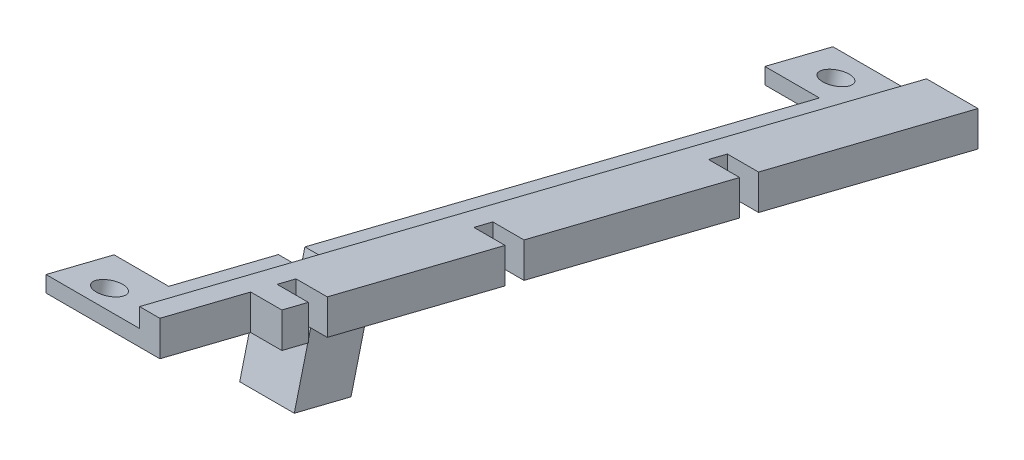
from build123d import *

# Parameters (mm, degrees)
SIDE_COMB_DEPTH           = 4
SIDE_COMB_2_DEPTH         = 4
SIDE_COMB_3_DEPTH         = 4
SIDE_COMB_4_DEPTH         = 4
SIDE_SPACER_DEPTH         = 2.6
NARROW_SUPPORT_DEPTH      = 5
SCREW_TABS_DEPTH          = 7
SKETCH5_R                 = 1.75
SCREW_HOLES_DEPTH         = 7
SKETCH7_W                 = 5
SKETCH7_H                 = 3.5
GAP_FOR_SUPPORT_BAR_DEPTH = 2
SUPPORT_BAR_SIDES_DEPTH   = 8.5
SKETCH8_W                 = 7
SKETCH8_H                 = 7.5
SUPPORT_BAR_BOTTOM_DEPTH  = 2


with BuildPart() as part:
    # Sketch1 → Side comb (new body)
    with BuildSketch(Plane(origin=(0, 0, 0), x_dir=(0, 0, -1), z_dir=(1, 0, 0))):
        Polygon((3.396035042, -0.846726635), (0, 0), (0, -4.5), (3.396035042, -5.346726635), align=None)
    extrude(amount=SIDE_COMB_DEPTH)



with BuildPart() as body_2:
    # Sketch1 → Side comb 2 (new body)
    with BuildSketch(Plane(origin=(0, 0, 0), x_dir=(0, 0, -1), z_dir=(1, 0, 0))):
        Polygon((28.623723925, -7.13669592), (5.821774358, -1.451531374), (5.821774358, -5.951531374), (28.623723925, -11.63669592), align=None)
    extrude(amount=SIDE_COMB_2_DEPTH)


with BuildPart() as body_3:
    # Sketch1 → Side comb 3 (new body)
    with BuildSketch(Plane(origin=(0, 0, 0), x_dir=(0, 0, -1), z_dir=(1, 0, 0))):
        Polygon((58.70289144, -14.636274684), (31.049463241, -7.741500659), (31.049463241, -12.241500659), (58.70289144, -19.136274684), align=None)
    extrude(amount=SIDE_COMB_3_DEPTH)


with BuildPart() as body_4:
    # Sketch1 → Side comb 4 (new body)
    with BuildSketch(Plane(origin=(0, 0, 0), x_dir=(0, 0, -1), z_dir=(1, 0, 0))):
        Polygon((89.267206817, -22.256814395), (61.128630755, -15.241079423), (61.128630755, -19.741079423), (89.267206817, -26.756814395), align=None)
    extrude(amount=SIDE_COMB_4_DEPTH)


with BuildPart() as part_1:
    add(part.part)

    add(body_2.part)  # Side spacer merges body 2

    add(body_3.part)  # Side spacer merges body 3

    add(body_4.part)  # Side spacer merges body 4
    # Sketch2 → Side spacer (add)
    with BuildSketch(Plane.ZY):
        Polygon((-89.267206817, -22.256814395), (-89.267206817, -26.756814395), (11.643548715, -1.596937253), (11.643548715, 2.903062747), align=None)
    extrude(amount=SIDE_SPACER_DEPTH)

    # Sketch3 → Narrow support (add)
    with BuildSketch(Plane.ZY.offset(2.6)):
        Polygon((-89.267206817, -24.695587136), (11.643548715, 0.464290006), (11.643548715, -1.596937253), (-89.267206817, -26.756814395), align=None)
    extrude(amount=NARROW_SUPPORT_DEPTH)

    # Sketch4 → Screw tabs (add)
    with BuildSketch(Plane.ZY.offset(7.6)):
        Polygon((-89.267206817, -24.695587136), (-80.534545281, -22.518290076), (-80.534545281, -24.579517335), (-89.267206817, -26.756814395), align=None)
        Polygon((11.643548715, 0.464290006), (11.643548715, -1.596937253), (2.910887179, -3.774234313), (2.910887179, -1.713007055), align=None)
    extrude(amount=SCREW_TABS_DEPTH)

    # Sketch5 → Screw holes (cut)
    with BuildSketch(Plane(origin=(0, -2.296040631, 0.572467225), x_dir=(1, 0, 0), z_dir=(0, 0.970295726, -0.241921896))):
        with Locations((-9.85, 88.089992525)):
            Circle(SKETCH5_R)
        with Locations((-9.85, -7.910007475)):
            Circle(SKETCH5_R)
    extrude(amount=-SCREW_HOLES_DEPTH, mode=Mode.SUBTRACT)

    # Sketch7 → Gap for support bar (cut)
    with BuildSketch(Plane(origin=(0, -4.236632084, 1.056311016), x_dir=(1, 0, 0), z_dir=(0, -0.970295726, 0.241921896))):
        with Locations((-5.1, -13.839992525)):
            Rectangle(SKETCH7_W, SKETCH7_H)
    extrude(amount=-GAP_FOR_SUPPORT_BAR_DEPTH, mode=Mode.SUBTRACT)

    # Sketch6 → Support bar sides (add)
    with BuildSketch(Plane(origin=(0, -4.236632084, 1.056311016), x_dir=(1, 0, 0), z_dir=(0, -0.970295726, 0.241921896))):
        Polygon((-2.6, -12.089992525), (-7.6, -12.089992525), (-7.6, -10.089992525), (-0.6, -10.089992525), (-0.6, -17.589992525), (-7.6, -17.589992525), (-7.6, -15.589992525), (-2.6, -15.589992525), align=None)
    extrude(amount=SUPPORT_BAR_SIDES_DEPTH)

    # Sketch8 → Support bar bottom (add)
    with BuildSketch(Plane(origin=(0, -12.484145757, 3.112647129), x_dir=(1, 0, 0), z_dir=(0, -0.970295726, 0.241921896))):
        with Locations((-4.1, -13.839992525)):
            Rectangle(SKETCH8_W, SKETCH8_H)
    extrude(amount=SUPPORT_BAR_BOTTOM_DEPTH)


solid = part_1.part
